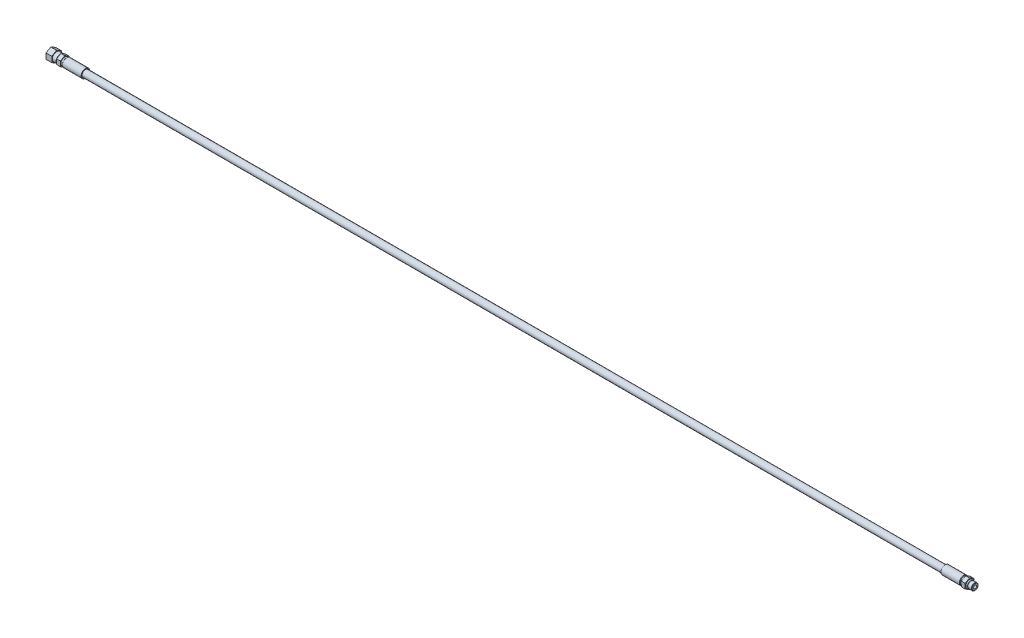
from build123d import *

# Parameters (mm, degrees)
SKETCH2_R          = 19.05
CUT_EXTRUDE1_DEPTH = 1498.219
CUT_EXTRUDE2_REACH = 1526
SKETCH3_R          = 19.05
CHAMFER1_SIZE      = 0.6858
SKETCH4_R          = 1.016


with BuildPart() as part:
    # Sketch1 → Revolve1 (revolve)
    with BuildSketch(Plane.XY, mode=Mode.PRIVATE) as revolve1_sk:
        Polygon((-1524, 2.413), (0, 2.413), (0, 5.5372), (-6.3246, 5.5372), (-7.239, 4.6228), (-9.144, 4.6228), (-9.144, 19.05), (-15.494, 19.05), (-15.494, 6.35), (-18.034, 6.35), (-18.796, 7.112), (-49.276, 7.112), (-49.276, 5.588), (-1466.85, 5.588), (-1466.85, 7.112), (-1497.711, 7.112), (-1498.473, 6.35), (-1501.013, 6.35), (-1501.013, 19.05), (-1507.363, 19.05), (-1507.363, 6.35), (-1508.125, 6.35), (-1508.125, 7.112), (-1514.475, 7.112), (-1514.475, 19.05), (-1524, 19.05), align=None)
    revolve(revolve1_sk.sketch.rotate(Axis((0, 0, 0), (1, 0, 0)), 90), axis=Axis((0, 0, 0), (1, 0, 0)))  # turned: the seam where the file's is

    # Sketch2 → Cut-Extrude1 (cut)
    with BuildSketch(Plane(origin=(-9.144, 0, 0), x_dir=(0, 0, -1), z_dir=(1, 0, 0))):
        with Locations(Location((0, 0, 0), (0, 0, 180))):  # turned: the seam where the file's is
            Circle(SKETCH2_R)
        Polygon((0, 8.212230229), (-7.112, 4.106115114), (-7.112, -4.106115114), (0, -8.212230229), (7.112, -4.106115114), (7.112, 4.106115114), align=None, mode=Mode.SUBTRACT)
    extrude(amount=-CUT_EXTRUDE1_DEPTH, mode=Mode.SUBTRACT)

    # Sketch3 → Cut-Extrude2 (cut, up to next)
    with BuildSketch(Plane.ZY.offset(1524), mode=Mode.PRIVATE) as cut_extrude2_sk1:
        Circle(SKETCH3_R)
        Polygon((0, 9.165435523), (-7.9375, 4.582717762), (-7.9375, -4.582717762), (0, -9.165435523), (7.9375, -4.582717762), (7.9375, 4.582717762), align=None, mode=Mode.SUBTRACT)
    cut_extrude2_tool1 = extrude(cut_extrude2_sk1.sketch, amount=-CUT_EXTRUDE2_REACH, mode=Mode.PRIVATE) & part.part
    add(cut_extrude2_tool1.solids().sort_by_distance((-1524, 0, -18.511185))[0], mode=Mode.SUBTRACT)

    # Chamfer1
    chamfer1_edges = [part.edges().sort_by_distance(p)[0] for p in [
        (0, 0, -5.5372),
    ]]
    chamfer(chamfer1_edges, length=CHAMFER1_SIZE)

    # Sketch5 → Cut-Revolve2 (revolve, cut)
    with BuildSketch(Plane.XY, mode=Mode.PRIVATE) as cut_revolve2_sk:
        Polygon((-1524, 6.199895345), (-1522.760724655, 4.96062), (-1511.3, 4.96062), (-1508.319358796, 0), (-1524, 0), align=None)
    revolve(cut_revolve2_sk.sketch.rotate(Axis((-576.489826751, 0, 0), (-1, 0, 0)), 270), axis=Axis((-576.489826751, 0, 0), (-1, 0, 0)), mode=Mode.SUBTRACT)  # turned: the seam where the file's is


with BuildPart() as body_2:
    # Sketch4 → Revolve5 (revolve)
    with BuildSketch(Plane.XY, mode=Mode.PRIVATE) as revolve5_sk:
        with Locations((-8.128, 5.588)):
            Circle(SKETCH4_R)
    revolve(revolve5_sk.sketch.rotate(Axis((0, 0, 0), (1, 0, 0)), 90), axis=Axis((0, 0, 0), (1, 0, 0)))  # turned: the seam where the file's is


solid = Compound([part.part, body_2.part])
